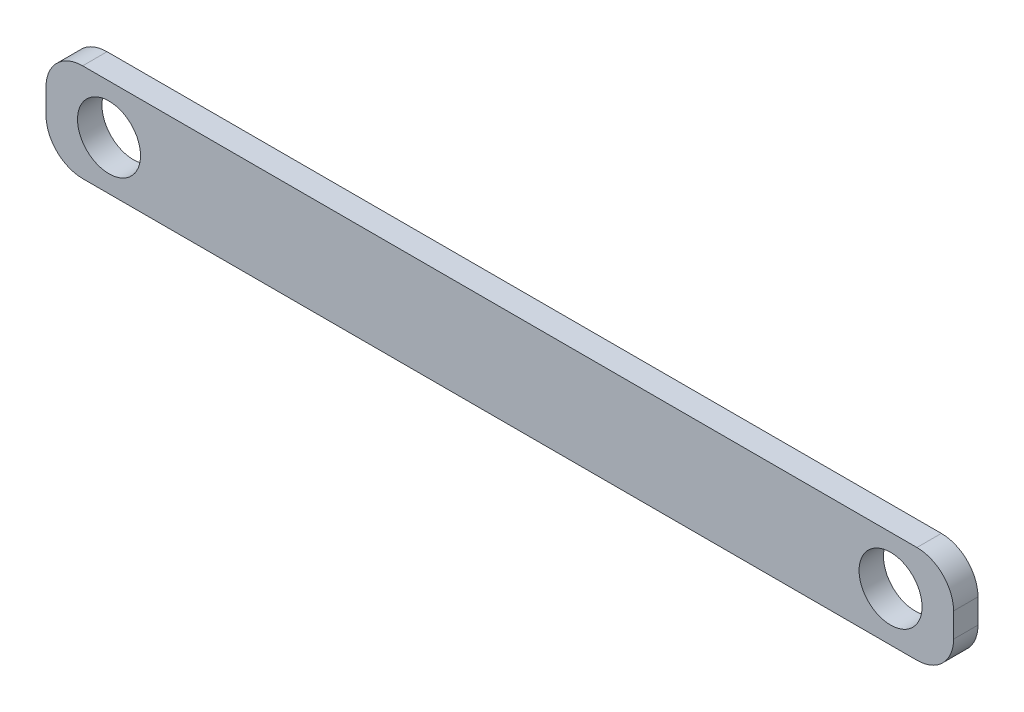
from build123d import *

# Parameters (mm, degrees)
SKETCH1_W           = 185.8
SKETCH1_H           = 20
SKETCH1_R           = 6.45
BOSS_EXTRUDE1_DEPTH = 5
FILLET1_R           = 7.5


with BuildPart() as part:
    # Sketch1 → Boss-Extrude1 (new body)
    with BuildSketch(Plane.XY):
        Rectangle(SKETCH1_W, SKETCH1_H)
        with Locations((-80, 0)):
            Circle(SKETCH1_R, mode=Mode.SUBTRACT)
        with Locations((80, 0)):
            Circle(SKETCH1_R, mode=Mode.SUBTRACT)
    extrude(amount=BOSS_EXTRUDE1_DEPTH)

    # Fillet1
    fillet1_edges = [part.edges().sort_by_distance(p)[0] for p in [
        (-92.9, 10, 2.5),
        (92.9, 10, 2.5),
        (92.9, -10, 2.5),
        (-92.9, -10, 2.5),
    ]]
    fillet(fillet1_edges, radius=FILLET1_R)


solid = part.part
